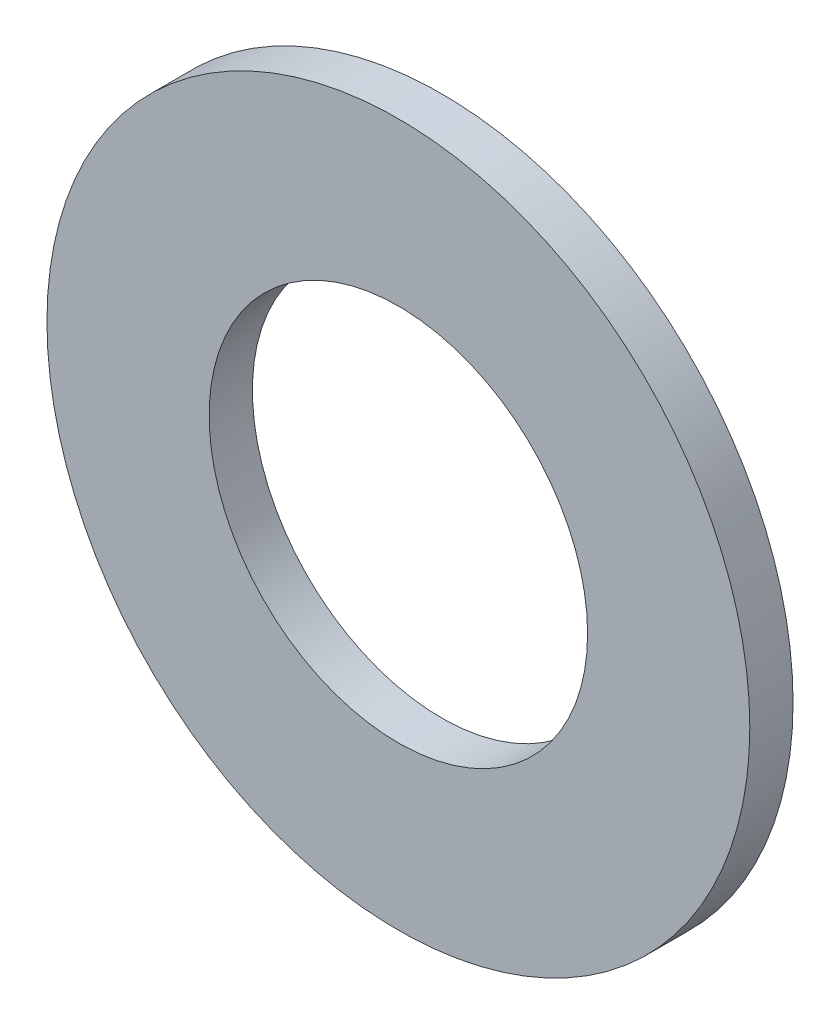
from build123d import *

# Parameters (mm, degrees)
SKETCH1_R           = 32.5
SKETCH1_R_2         = 17.5
BOSS_EXTRUDE1_DEPTH = 4


with BuildPart() as part:
    # Sketch1 → Boss-Extrude1 (new body)
    with BuildSketch(Plane.XY):
        Circle(SKETCH1_R)
        Circle(SKETCH1_R_2, mode=Mode.SUBTRACT)
    extrude(amount=BOSS_EXTRUDE1_DEPTH)


solid = part.part
